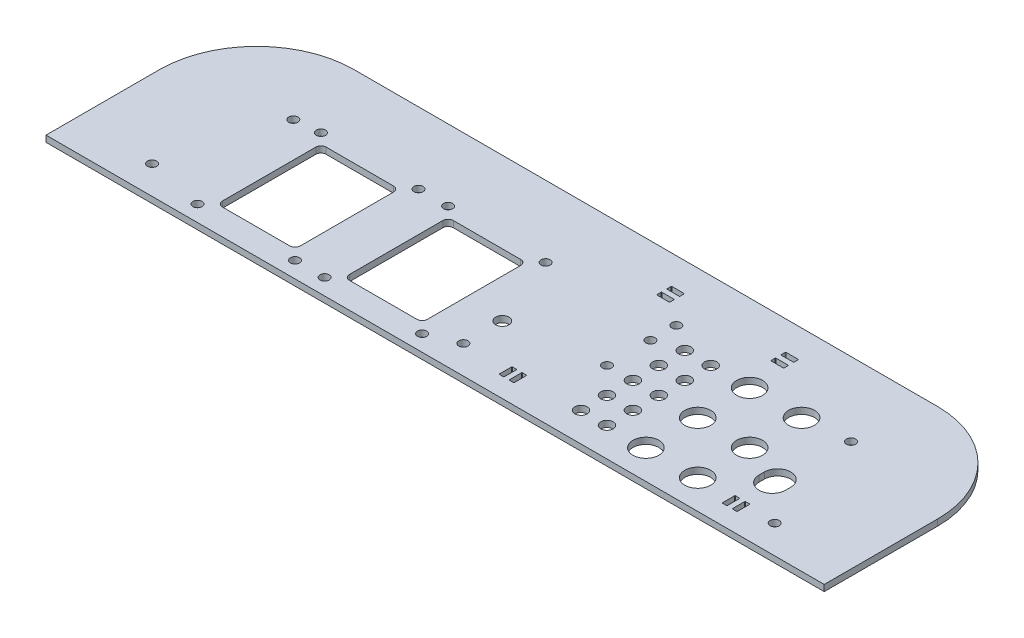
from build123d import *

# Parameters (mm, degrees)
BOSS_EXTRUDE1_DEPTH             = 3.0734
L_BRACKET_MOUNT_HOLES_8_D       = 4.4958
SKETCH6_R                       = 6.35
ATLAS_SENSORS_DEPTH             = 4.0734
ATLAS_SENSOR_PATTERN_COUNT      = 3
ATLAS_SENSOR_PATTERN_PITCH      = 25.4
ATLAS_SENSOR_PATTERN_COUNT_DIR2 = 2
ATLAS_SENSOR_PATTERN_PITCH_DIR2 = 25.4
NUTRIENT_START                  = -4.0734
SKETCH7_R                       = 3.0226
NUTRIENT_HOSES_DEPTH            = 5.0734
LPATTERN2_COUNT                 = 2
LPATTERN2_PITCH                 = 12.7
LPATTERN2_COUNT_DIR2            = 5
LPATTERN2_PITCH_DIR2            = 12.7
WATER_LEVEL_SENSOR_D            = 4.4958
TEMP_SENSOR_MOUNTING_DEPTH      = 4.0734
SKETCH12_W                      = 38.1
SKETCH12_H                      = 50.8
ACCESSORY_HOLE_DEPTH            = 4.0734
FILLET1_R                       = 2.54
F_8_CLEARANCE_HOLE3_D           = 4.4958
LPATTERN3_COUNT                 = 2
LPATTERN3_PITCH                 = 62.23
FILLET1_OF_LPATTERN3_R          = 2.54
PUMP_WIRE_ZIP_TIE_DEPTH         = 4.0734
WIRE_ZIP_TIE_DEPTH              = 4.0734
LPATTERN4_COUNT                 = 2
LPATTERN4_PITCH                 = 55.88
F_1_4_CLEARANCE_HOLE1_D         = 6.5278


with BuildPart() as part:
    # Sketch1 → Boss-Extrude1 (new body)
    with BuildSketch(Plane(origin=(0, 0, 0), x_dir=(1, 0, 0), z_dir=(0, 1, 0))):
        with BuildLine():
            Line((0, 0), (381, 0))
            Line((381, 0), (381, 55.5625))
            ThreePointArc((381, 55.5625), (367.050960454, 89.238460454), (333.375, 103.1875))
            Line((333.375, 103.1875), (47.625, 103.1875))
            ThreePointArc((47.625, 103.1875), (13.949039546, 89.238460454), (0, 55.5625))
            Line((0, 55.5625), (0, 0))
        make_face()
    extrude(amount=BOSS_EXTRUDE1_DEPTH)

    # L Bracket Mount Holes (#8) (through all)
    with Locations(Plane(origin=(0, 3.0734, 0), x_dir=(1, 0, 0), z_dir=(0, 1, 0))):
        with Locations((38.1, 13.8557), (342.9, 13.8557), (53.975, 67.1068), (327.025, 67.1068), (190.5, 13.8557)):
            Hole(L_BRACKET_MOUNT_HOLES_8_D / 2)

    # Sketch6 → Atlas Sensors (cut, through all)
    with BuildSketch(Plane(origin=(0, 3.0734, 0), x_dir=(1, 0, 0), z_dir=(0, 1, 0))):
        with Locations((304.8, 65.0875)):
            Circle(SKETCH6_R)
    atlas_sensors = extrude(amount=-ATLAS_SENSORS_DEPTH, mode=Mode.SUBTRACT)

    # Atlas Sensor Pattern: Atlas Sensors 3 × 2
    with Locations(*[(-j * ATLAS_SENSOR_PATTERN_PITCH_DIR2, 0, i * ATLAS_SENSOR_PATTERN_PITCH) for i in range(ATLAS_SENSOR_PATTERN_COUNT) for j in range(ATLAS_SENSOR_PATTERN_COUNT_DIR2) if (i, j) != (0, 0)]):
        add(atlas_sensors, mode=Mode.SUBTRACT)

    # Sketch7 → Nutrient Hoses (cut)
    with BuildSketch(Plane(origin=(0, 3.0734, 0), x_dir=(1, 0, 0), z_dir=(0, 1, 0)).offset(NUTRIENT_START)):
        with Locations((260.35, 65.0875)):
            Circle(SKETCH7_R)
    nutrient_hoses = extrude(amount=NUTRIENT_HOSES_DEPTH, mode=Mode.SUBTRACT)

    # LPattern2: Nutrient Hoses 2 × 5
    with Locations(*[(-i * LPATTERN2_PITCH, 0, j * LPATTERN2_PITCH_DIR2) for i in range(LPATTERN2_COUNT) for j in range(LPATTERN2_COUNT_DIR2) if (i, j) != (0, 0)]):
        add(nutrient_hoses, mode=Mode.SUBTRACT)

    # Water Level Sensor (through all)
    with Locations(Plane(origin=(0, 3.0734, 0), x_dir=(1, 0, 0), z_dir=(0, 1, 0))):
        with Locations((234.95, 60.9473), (234.95, 39.6875), (234.95, 73.6473)):
            Hole(WATER_LEVEL_SENSOR_D / 2)

    # Sketch10 → temp sensor mounting (cut, through all)
    with BuildSketch(Plane(origin=(0, 3.0734, 0), x_dir=(1, 0, 0), z_dir=(0, 1, 0))):
        with BuildLine():
            Line((321.46875, 9.779), (321.46875, 15.621))
            ThreePointArc((321.46875, 15.621), (321.543144878, 15.800605122), (321.72275, 15.875))
            Line((321.72275, 15.875), (323.596, 15.875))
            ThreePointArc((323.596, 15.875), (323.775605122, 15.800605122), (323.85, 15.621))
            Line((323.85, 15.621), (323.85, 9.779))
            ThreePointArc((323.85, 9.779), (323.775605122, 9.599394878), (323.596, 9.525))
            Line((323.596, 9.525), (321.72275, 9.525))
            ThreePointArc((321.72275, 9.525), (321.543144878, 9.599394878), (321.46875, 9.779))
        make_face()
        with BuildLine():
            Line((326.644, 9.525), (328.51725, 9.525))
            ThreePointArc((328.51725, 9.525), (328.696855122, 9.599394878), (328.77125, 9.779))
            Line((328.77125, 9.779), (328.77125, 15.621))
            ThreePointArc((328.77125, 15.621), (328.696855122, 15.800605122), (328.51725, 15.875))
            Line((328.51725, 15.875), (326.644, 15.875))
            ThreePointArc((326.644, 15.875), (326.464394878, 15.800605122), (326.39, 15.621))
            Line((326.39, 15.621), (326.39, 9.779))
            ThreePointArc((326.39, 9.779), (326.464394878, 9.599394878), (326.644, 9.525))
        make_face()
        with BuildLine():
            Line((318.643, 30.48), (318.643, 33.02))
            ThreePointArc((318.643, 33.02), (325.12, 39.497), (331.597, 33.02))
            Line((331.597, 33.02), (331.597, 30.48))
            ThreePointArc((331.597, 30.48), (325.12, 24.003), (318.643, 30.48))
        make_face()
    extrude(amount=-TEMP_SENSOR_MOUNTING_DEPTH, mode=Mode.SUBTRACT)

    # Sketch12 → Accessory Hole (cut, through all)
    with BuildSketch(Plane(origin=(0, 3.0734, 0), x_dir=(1, 0, 0), z_dir=(0, 1, 0))):
        with Locations((152.4, 38.1)):
            Rectangle(SKETCH12_W, SKETCH12_H)
    accessory_hole = extrude(amount=-ACCESSORY_HOLE_DEPTH, mode=Mode.SUBTRACT)

    # Fillet1
    fillet1_edges = [part.edges().sort_by_distance(p)[0] for p in [
        (133.35, 1.5367, -12.7),
        (133.35, 1.5367, -63.5),
        (171.45, 1.5367, -63.5),
        (171.45, 1.5367, -12.7),
    ]]
    fillet(fillet1_edges, radius=FILLET1_R)

    # #8 Clearance Hole3 (through all)
    with Locations(Plane(origin=(0, 3.0734, 0), x_dir=(1, 0, 0), z_dir=(0, 1, 0))):
        with Locations((128.524, 68.326), (176.276, 68.326), (176.276, 7.874), (128.524, 7.874)):
            f_8_clearance_hole3 = Hole(F_8_CLEARANCE_HOLE3_D / 2)

    # LPattern3: Accessory Hole, #8 Clearance Hole3 ×2
    with Locations(*[(-i * LPATTERN3_PITCH, 0, 0) for i in range(1, LPATTERN3_COUNT)]):
        add(accessory_hole, mode=Mode.SUBTRACT)
        add(f_8_clearance_hole3, mode=Mode.SUBTRACT)

    # Fillet1 of LPattern3
    fillet1_of_lpattern3_edges = [part.edges().sort_by_distance(p)[0] for p in [
        (71.12, 1.5367, -12.7),
        (71.12, 1.5367, -63.5),
        (109.22, 1.5367, -63.5),
        (109.22, 1.5367, -12.7),
    ]]
    fillet(fillet1_of_lpattern3_edges, radius=FILLET1_OF_LPATTERN3_R)

    # Sketch16 → Pump Wire zip tie (cut, through all)
    with BuildSketch(Plane(origin=(0, 3.0734, 0), x_dir=(1, 0, 0), z_dir=(0, 1, 0))):
        with BuildLine():
            Line((212.50275, 15.875), (214.376, 15.875))
            ThreePointArc((214.376, 15.875), (214.555605122, 15.800605122), (214.63, 15.621))
            Line((214.63, 15.621), (214.63, 9.779))
            ThreePointArc((214.63, 9.779), (214.555605122, 9.599394878), (214.376, 9.525))
            Line((214.376, 9.525), (212.50275, 9.525))
            ThreePointArc((212.50275, 9.525), (212.323144878, 9.599394878), (212.24875, 9.779))
            Line((212.24875, 9.779), (212.24875, 15.621))
            ThreePointArc((212.24875, 15.621), (212.323144878, 15.800605122), (212.50275, 15.875))
        make_face()
        with BuildLine():
            Line((219.29725, 9.525), (217.424, 9.525))
            ThreePointArc((217.424, 9.525), (217.244394878, 9.599394878), (217.17, 9.779))
            Line((217.17, 9.779), (217.17, 15.621))
            ThreePointArc((217.17, 15.621), (217.244394878, 15.800605122), (217.424, 15.875))
            Line((217.424, 15.875), (219.29725, 15.875))
            ThreePointArc((219.29725, 15.875), (219.476855122, 15.800605122), (219.55125, 15.621))
            Line((219.55125, 15.621), (219.55125, 9.779))
            ThreePointArc((219.55125, 9.779), (219.476855122, 9.599394878), (219.29725, 9.525))
        make_face()
    extrude(amount=-PUMP_WIRE_ZIP_TIE_DEPTH, mode=Mode.SUBTRACT)

    # Sketch18 → Wire Zip Tie (cut, through all)
    with BuildSketch(Plane(origin=(0, 3.0734, 0), x_dir=(1, 0, 0), z_dir=(0, 1, 0))):
        with BuildLine():
            Line((273.304, 89.05875), (279.146, 89.05875))
            ThreePointArc((279.146, 89.05875), (279.325605122, 88.984355122), (279.4, 88.80475))
            Line((279.4, 88.80475), (279.4, 86.9315))
            ThreePointArc((279.4, 86.9315), (279.325605122, 86.751894878), (279.146, 86.6775))
            Line((279.146, 86.6775), (273.304, 86.6775))
            ThreePointArc((273.304, 86.6775), (273.124394878, 86.751894878), (273.05, 86.9315))
            Line((273.05, 86.9315), (273.05, 88.80475))
            ThreePointArc((273.05, 88.80475), (273.124394878, 88.984355122), (273.304, 89.05875))
        make_face()
        with BuildLine():
            Line((279.4, 82.01025), (279.4, 83.8835))
            ThreePointArc((279.4, 83.8835), (279.325605122, 84.063105122), (279.146, 84.1375))
            Line((279.146, 84.1375), (273.304, 84.1375))
            ThreePointArc((273.304, 84.1375), (273.124394878, 84.063105122), (273.05, 83.8835))
            Line((273.05, 83.8835), (273.05, 82.01025))
            ThreePointArc((273.05, 82.01025), (273.124394878, 81.830644878), (273.304, 81.75625))
            Line((273.304, 81.75625), (279.146, 81.75625))
            ThreePointArc((279.146, 81.75625), (279.325605122, 81.830644878), (279.4, 82.01025))
        make_face()
    wire_zip_tie = extrude(amount=-WIRE_ZIP_TIE_DEPTH, mode=Mode.SUBTRACT)

    # LPattern4: Wire Zip Tie ×2
    with Locations(*[(-i * LPATTERN4_PITCH, 0, 0) for i in range(1, LPATTERN4_COUNT)]):
        add(wire_zip_tie, mode=Mode.SUBTRACT)

    # 1/4 Clearance Hole1 (through all)
    with Locations(Plane(origin=(0, 3.0734, 0), x_dir=(1, 0, 0), z_dir=(0, 1, 0))):
        with Locations((190.5, 32.9057)):
            Hole(F_1_4_CLEARANCE_HOLE1_D / 2)


solid = part.part
